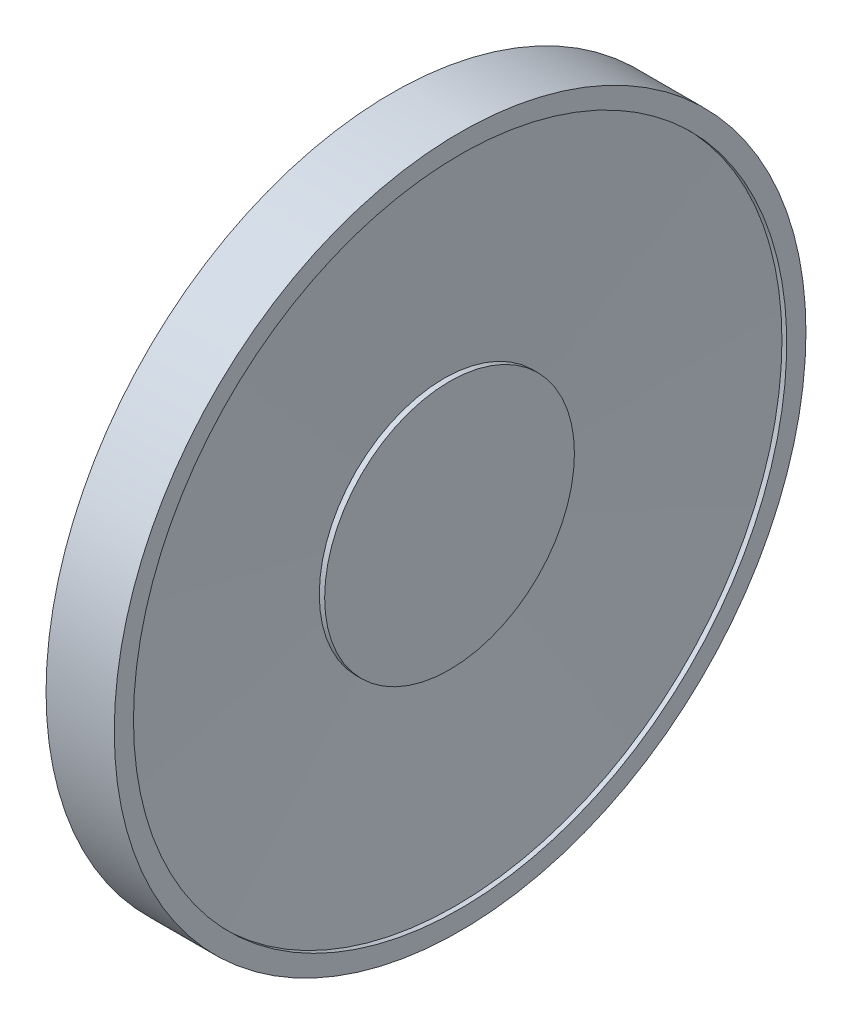
from build123d import *

# Parameters (mm, degrees)
SKETCH2_R           = 8.75
BOSS_EXTRUDE2_DEPTH = 3.5
SKETCH3_R           = 16.5
BOSS_EXTRUDE3_DEPTH = 1.5
SKETCH5_R           = 18
SKETCH5_R_2         = 17
BOSS_EXTRUDE4_DEPTH = 3.55
SKETCH6_R           = 17
SKETCH6_R_2         = 15
BOSS_EXTRUDE5_DEPTH = 1.5
SKETCH8_R           = 6.5
BOSS_EXTRUDE6_DEPTH = 0.75
BOSS_EXTRUDE7_DEPTH = 0.4


with BuildPart() as part:
    # Sketch2 → Boss-Extrude2 (new body)
    with BuildSketch(Plane(origin=(0, 0, 0), x_dir=(0, 0, -1), z_dir=(1, 0, 0))):
        Circle(SKETCH2_R)
    extrude(amount=BOSS_EXTRUDE2_DEPTH)

    # Sketch3 → Boss-Extrude3 (add)
    with BuildSketch(Plane.ZY.offset(-0.5)):
        Circle(SKETCH3_R)
    extrude(amount=-BOSS_EXTRUDE3_DEPTH)



with BuildPart() as body_2:
    # Sketch5 → Boss-Extrude4 (new body)
    with BuildSketch(Plane(origin=(1.25, 0, 0), x_dir=(0, 0, -1), z_dir=(1, 0, 0))):
        Circle(SKETCH5_R)
        Circle(SKETCH5_R_2, mode=Mode.SUBTRACT)
    extrude(amount=BOSS_EXTRUDE4_DEPTH)


with BuildPart() as part_1:
    add(part.part)

    add(body_2.part)  # Boss-Extrude5 merges body 2
    # Sketch6 → Boss-Extrude5 (add)
    with BuildSketch(Plane(origin=(1.25, 0, 0), x_dir=(0, 0, -1), z_dir=(1, 0, 0))):
        Circle(SKETCH6_R)
        Circle(SKETCH6_R_2, mode=Mode.SUBTRACT)
    extrude(amount=BOSS_EXTRUDE5_DEPTH)

    # Sketch8 → Boss-Extrude6 (add)
    with BuildSketch(Plane(origin=(3.5, 0, 0), x_dir=(0, 0, -1), z_dir=(1, 0, 0))):
        Circle(SKETCH8_R)
    extrude(amount=BOSS_EXTRUDE6_DEPTH)

    # Sketch10 → Revolve1 (revolve)
    with BuildSketch(Plane(origin=(0, 0, 0), x_dir=(1, 0, 0), z_dir=(0, 1, 0))):
        Polygon((1.25, 0), (3.611187211, 0), (4.55, 17), (2.75, 17), align=None)
    revolve(axis=Axis((1.25, 0, 0), (1, 0, 0)))

    # Sketch11 → Boss-Extrude7 (add)
    with BuildSketch(Plane.ZY.offset(-0.5)):
        with BuildLine():
            Line((8.25, -14.289419162), (4.375, -7.577722283))
            ThreePointArc((4.375, -7.577722283), (0, -8.75), (-4.375, -7.577722283))
            Line((-4.375, -7.577722283), (-8.25, -14.289419162))
            ThreePointArc((-8.25, -14.289419162), (0, -16.5), (8.25, -14.289419162))
        make_face()
    extrude(amount=BOSS_EXTRUDE7_DEPTH)


solid = part_1.part
